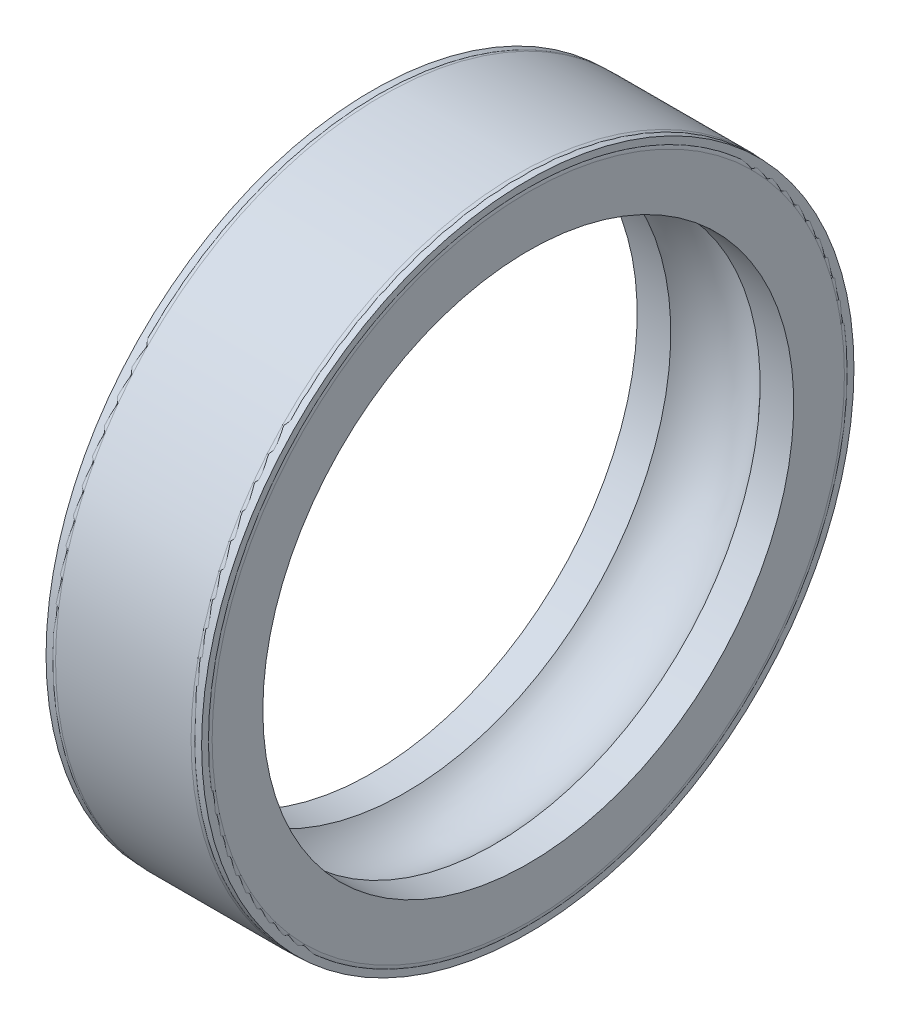
from build123d import *

# Parameters (mm, degrees)
FILLET5_R = 53.34


with BuildPart() as part:
    # Sketch1 → Revolve-Thin1 (revolve)
    with BuildSketch(Plane(origin=(0, 0, 0), x_dir=(1, 0, 0), z_dir=(0, 1, 0))):
        with BuildLine():
            Line((-226.045729887, 1340.828010817), (-396.24, 1340.828010817))
            Line((-396.24, 1340.828010817), (-396.24, 1650.708010817))
            Line((-396.24, 1650.708010817), (396.24, 1650.708010817))
            Line((396.24, 1650.708010817), (396.24, 1340.828010817))
            Line((396.24, 1340.828010817), (226.045729887, 1340.828010817))
            ThreePointArc((226.045729887, 1340.828010817), (0, 1442.428010817), (-226.045729887, 1340.828010817))
        make_face()
        with BuildLine():
            Line((-227.184506514, 1343.368010817), (-393.7, 1343.368010817))
            Line((-393.7, 1343.368010817), (-393.7, 1648.168010817))
            Line((-393.7, 1648.168010817), (393.7, 1648.168010817))
            Line((393.7, 1648.168010817), (393.7, 1343.368010817))
            Line((393.7, 1343.368010817), (227.184506514, 1343.368010817))
            ThreePointArc((227.184506514, 1343.368010817), (0, 1444.968010817), (-227.184506514, 1343.368010817))
        make_face(mode=Mode.SUBTRACT)
    revolve(axis=Axis((-398.62261829, 0, 2.831989183), (1, 0, 0)))

    # Fillet5
    fillet5_edges = [part.edges().sort_by_distance(p)[0] for p in [
        (-396.24, 0, 1656.371989183),
        (396.24, 0, 1656.371989183),
    ]]
    fillet(fillet5_edges, radius=FILLET5_R)


solid = part.part
